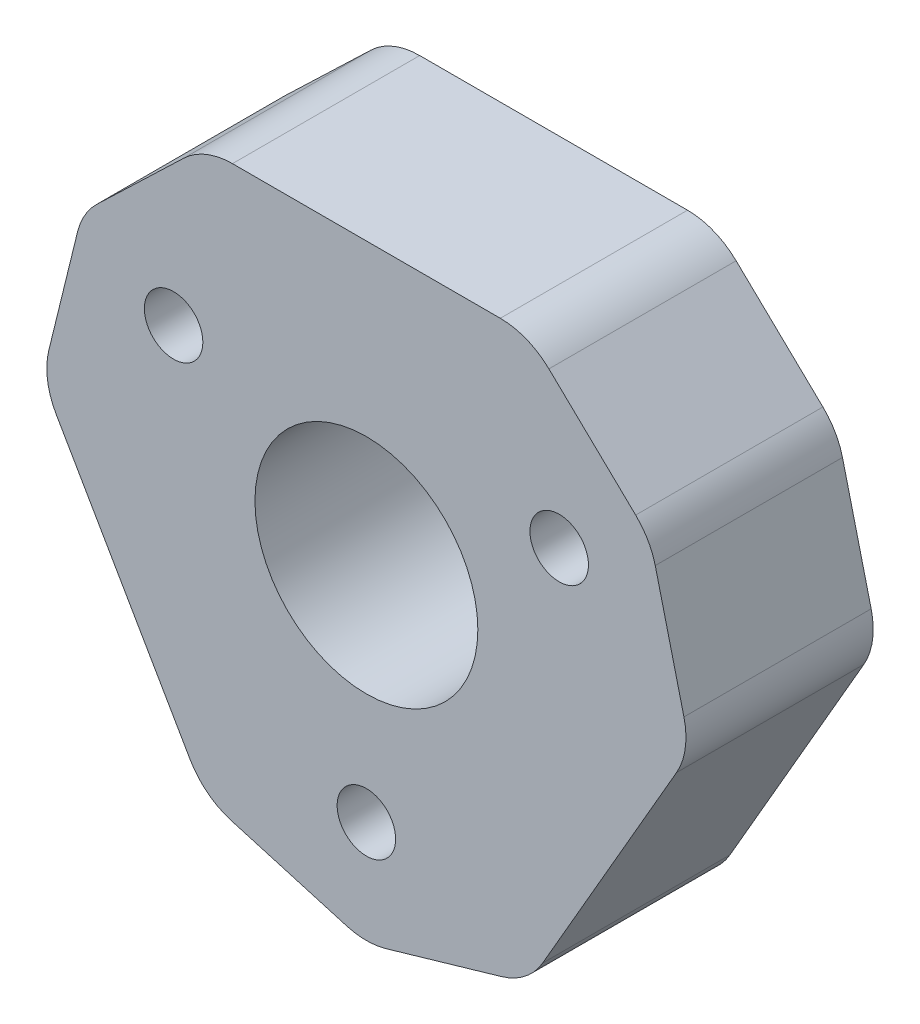
from build123d import *

# Parameters (mm, degrees)
SKETCH1_R           = 4.7625
SKETCH1_R_2         = 1.25
BOSS_EXTRUDE1_DEPTH = 8


with BuildPart() as part:
    # Sketch1 → Boss-Extrude1 (new body)
    with BuildSketch(Plane.XY):
        with BuildLine():
            Line((-13.253372163, -1.044486042), (-7.531237528, -10.955513958))
            ThreePointArc((-7.531237528, -10.955513958), (-6.784217233, -11.816359568), (-5.770008435, -12.336431676))
            Line((-5.770008435, -12.336431676), (-0.836847118, -13.76941319))
            ThreePointArc((-0.836847118, -13.76941319), (0, -13.888495471), (0.836847118, -13.76941319))
            Line((0.836847118, -13.76941319), (5.770008435, -12.336431676))
            ThreePointArc((5.770008435, -12.336431676), (6.784217233, -11.816359568), (7.531237528, -10.955513958))
            Line((7.531237528, -10.955513958), (13.253372163, -1.044486042))
            ThreePointArc((13.253372163, -1.044486042), (13.625376182, 0.032875315), (13.568667441, 1.171241953))
            Line((13.568667441, 1.171241953), (12.343085176, 6.159975731))
            ThreePointArc((12.343085176, 6.159975731), (12.027789898, 6.944247736), (11.506238058, 7.609437458))
            Line((11.506238058, 7.609437458), (7.798659006, 11.165189723))
            ThreePointArc((7.798659006, 11.165189723), (6.841158949, 11.783484253), (5.722134635, 12))
            Line((5.722134635, 12), (-5.722134635, 12))
            ThreePointArc((-5.722134635, 12), (-6.841158949, 11.783484253), (-7.798659006, 11.165189723))
            Line((-7.798659006, 11.165189723), (-11.506238058, 7.609437458))
            ThreePointArc((-11.506238058, 7.609437458), (-12.027789898, 6.944247736), (-12.343085176, 6.159975731))
            Line((-12.343085176, 6.159975731), (-13.568667441, 1.171241953))
            ThreePointArc((-13.568667441, 1.171241953), (-13.625376182, 0.032875315), (-13.253372163, -1.044486042))
        make_face()
        Circle(SKETCH1_R, mode=Mode.SUBTRACT)
        with Locations((-8.238066653, 4.75625)):
            Circle(SKETCH1_R_2, mode=Mode.SUBTRACT)
        with Locations((8.238066653, 4.75625)):
            Circle(SKETCH1_R_2, mode=Mode.SUBTRACT)
        with Locations((0, -9.5125)):
            Circle(SKETCH1_R_2, mode=Mode.SUBTRACT)
    extrude(amount=BOSS_EXTRUDE1_DEPTH)


solid = part.part
